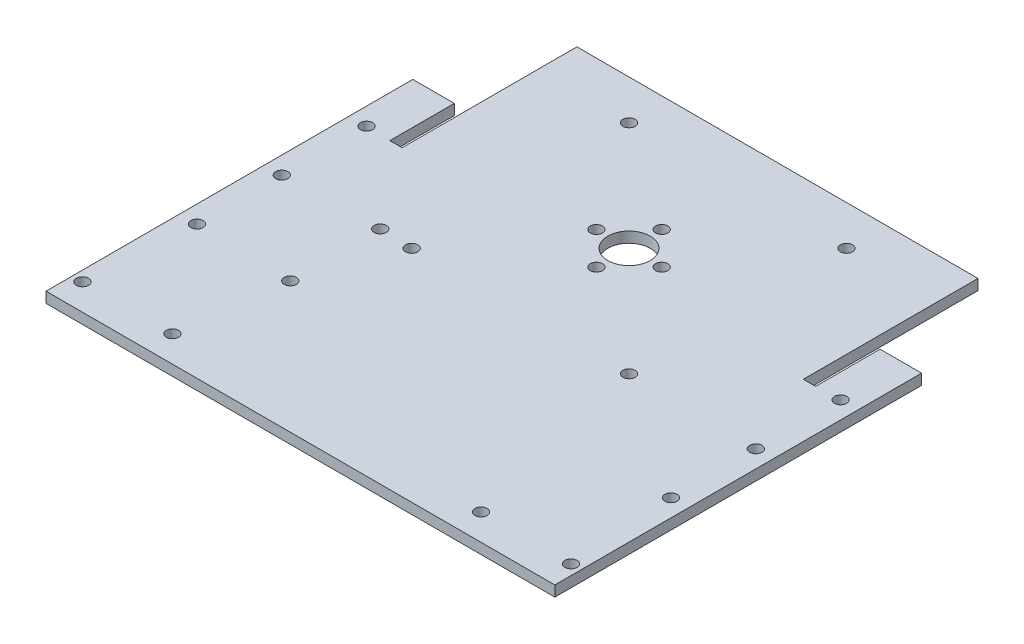
from build123d import *

# Parameters (mm, degrees)
SKETCH1_W           = 152.4
SKETCH1_H           = 88.9
BOSS_EXTRUDE1_DEPTH = 3.175
SKETCH2_W           = 3.175
SKETCH2_H           = 44.45
CUT_EXTRUDE1_DEPTH  = 4.175
SKETCH3_R           = 1.8288
CUT_EXTRUDE2_DEPTH  = 4.175
SKETCH6_W           = 3.175
SKETCH6_H           = 25.4
BOSS_EXTRUDE2_DEPTH = 3.175
CUT_EXTRUDE3_DEPTH  = 4.175
CUT_EXTRUDE4_DEPTH  = 4.175
SKETCH9_W           = 152.4
SKETCH9_H           = 20.955
BOSS_EXTRUDE3_DEPTH = 3.175
SKETCH10_R          = 1.8288
CUT_EXTRUDE5_DEPTH  = 4.175
SKETCH11_W          = 120.142
SKETCH11_H          = 88.9
BOSS_EXTRUDE4_DEPTH = 3.175
SKETCH12_R          = 6.35
CUT_EXTRUDE6_DEPTH  = 4.175
SKETCH13_R          = 1.8288
CUT_EXTRUDE7_DEPTH  = 4.175
SKETCH14_R          = 1.8288
CUT_EXTRUDE8_DEPTH  = 101.6
SKETCH15_R          = 1.8288
CUT_EXTRUDE9_DEPTH  = 4.175


with BuildPart() as part:
    # Sketch1 → Boss-Extrude1 (new body)
    with BuildSketch(Plane(origin=(0, 0, 0), x_dir=(1, 0, 0), z_dir=(0, 1, 0))):
        Rectangle(SKETCH1_W, SKETCH1_H)
    extrude(amount=BOSS_EXTRUDE1_DEPTH)

    # Sketch2 → Cut-Extrude1 (cut, through all)
    with BuildSketch(Plane(origin=(0, 3.175, 0), x_dir=(1, 0, 0), z_dir=(0, 1, 0))):
        with Locations((61.9125, 22.225)):
            Rectangle(SKETCH2_W, SKETCH2_H)
        with Locations((-61.9125, 22.225)):
            Rectangle(SKETCH2_W, SKETCH2_H)
    extrude(amount=-CUT_EXTRUDE1_DEPTH, mode=Mode.SUBTRACT)

    # Sketch3 → Cut-Extrude2 (cut, through all)
    with BuildSketch(Plane(origin=(0, 3.175, 0), x_dir=(1, 0, 0), z_dir=(0, 1, 0))):
        with Locations((-70.993, -25.4)):
            Circle(SKETCH3_R)
        with Locations((-70.993, 0)):
            Circle(SKETCH3_R)
        with Locations((-70.993, 25.4)):
            Circle(SKETCH3_R)
        with Locations((70.993, -25.4)):
            Circle(SKETCH3_R)
        with Locations((70.993, 0)):
            Circle(SKETCH3_R)
        with Locations((70.993, 25.4)):
            Circle(SKETCH3_R)
    extrude(amount=-CUT_EXTRUDE2_DEPTH, mode=Mode.SUBTRACT)

    # Sketch6 → Boss-Extrude2 (add)
    with BuildSketch(Plane(origin=(0, 3.175, 0), x_dir=(1, 0, 0), z_dir=(0, 1, 0))):
        with Locations((-61.9125, 12.7)):
            Rectangle(SKETCH6_W, SKETCH6_H)
        with Locations((61.9125, 12.7)):
            Rectangle(SKETCH6_W, SKETCH6_H)
    extrude(amount=-BOSS_EXTRUDE2_DEPTH)

    # Sketch7 → Cut-Extrude3 (cut, through all)
    with BuildSketch(Plane(origin=(0, 3.175, 0), x_dir=(1, 0, 0), z_dir=(0, 1, 0))):
        Polygon((-63.754, 44.45), (-63.5, 44.45), (-63.5, 25.4), (-60.325, 25.4), (-60.325, 44.45), (-60.071, 44.45), (-60.071, 25.146), (-63.754, 25.146), align=None)
    extrude(amount=-CUT_EXTRUDE3_DEPTH, mode=Mode.SUBTRACT)

    # Sketch8 → Cut-Extrude4 (cut, through all)
    with BuildSketch(Plane(origin=(0, 3.175, 0), x_dir=(1, 0, 0), z_dir=(0, 1, 0))):
        Polygon((60.071, 44.45), (60.325, 44.45), (60.325, 25.4), (63.5, 25.4), (63.5, 44.45), (63.754, 44.45), (63.754, 25.146), (60.071, 25.146), align=None)
    extrude(amount=-CUT_EXTRUDE4_DEPTH, mode=Mode.SUBTRACT)

    # Sketch9 → Boss-Extrude3 (add)
    with BuildSketch(Plane(origin=(0, 3.175, 0), x_dir=(1, 0, 0), z_dir=(0, 1, 0))):
        with Locations((0, -54.9275)):
            Rectangle(SKETCH9_W, SKETCH9_H)
    extrude(amount=-BOSS_EXTRUDE3_DEPTH)

    # Sketch10 → Cut-Extrude5 (cut, through all)
    with BuildSketch(Plane(origin=(0, 3.175, 0), x_dir=(1, 0, 0), z_dir=(0, 1, 0))):
        with Locations((-73.1647, -57.531)):
            Circle(SKETCH10_R)
        with Locations((-46.2153, -57.531)):
            Circle(SKETCH10_R)
        with Locations((46.2153, -57.531)):
            Circle(SKETCH10_R)
        with Locations((73.1647, -57.531)):
            Circle(SKETCH10_R)
    extrude(amount=-CUT_EXTRUDE5_DEPTH, mode=Mode.SUBTRACT)

    # Sketch11 → Boss-Extrude4 (add)
    with BuildSketch(Plane(origin=(0, 3.175, 0), x_dir=(1, 0, 0), z_dir=(0, 1, 0))):
        with Locations((0, 33.02)):
            Rectangle(SKETCH11_W, SKETCH11_H)
    extrude(amount=-BOSS_EXTRUDE4_DEPTH)

    # Sketch12 → Cut-Extrude6 (cut, through all)
    with BuildSketch(Plane(origin=(0, 3.175, 0), x_dir=(1, 0, 0), z_dir=(0, 1, 0))):
        with Locations((0, 33.02)):
            Circle(SKETCH12_R)
    extrude(amount=-CUT_EXTRUDE6_DEPTH, mode=Mode.SUBTRACT)

    # Sketch13 → Cut-Extrude7 (cut, through all)
    with BuildSketch(Plane(origin=(0, 3.175, 0), x_dir=(1, 0, 0), z_dir=(0, 1, 0))):
        with Locations((32.5501, 0.4699)):
            Circle(SKETCH13_R)
        with Locations((-32.5501, 0.4699)):
            Circle(SKETCH13_R)
        with Locations((-32.5501, 65.5701)):
            Circle(SKETCH13_R)
        with Locations((32.5501, 65.5701)):
            Circle(SKETCH13_R)
    extrude(amount=-CUT_EXTRUDE7_DEPTH, mode=Mode.SUBTRACT)

    # Sketch14 → Cut-Extrude8 (cut)
    with BuildSketch(Plane.XZ):
        with Locations((0, -23.241)):
            Circle(SKETCH14_R)
        with Locations((-9.779, -33.02)):
            Circle(SKETCH14_R)
        with Locations((0, -42.799)):
            Circle(SKETCH14_R)
        with Locations((9.779, -33.02)):
            Circle(SKETCH14_R)
    extrude(amount=-CUT_EXTRUDE8_DEPTH, mode=Mode.SUBTRACT)

    # Sketch15 → Cut-Extrude9 (cut, through all)
    with BuildSketch(Plane.XZ):
        with Locations((-42.291, 26.162)):
            Circle(SKETCH15_R)
        with Locations((-42.291, -0.7874)):
            Circle(SKETCH15_R)
    extrude(amount=-CUT_EXTRUDE9_DEPTH, mode=Mode.SUBTRACT)


solid = part.part
